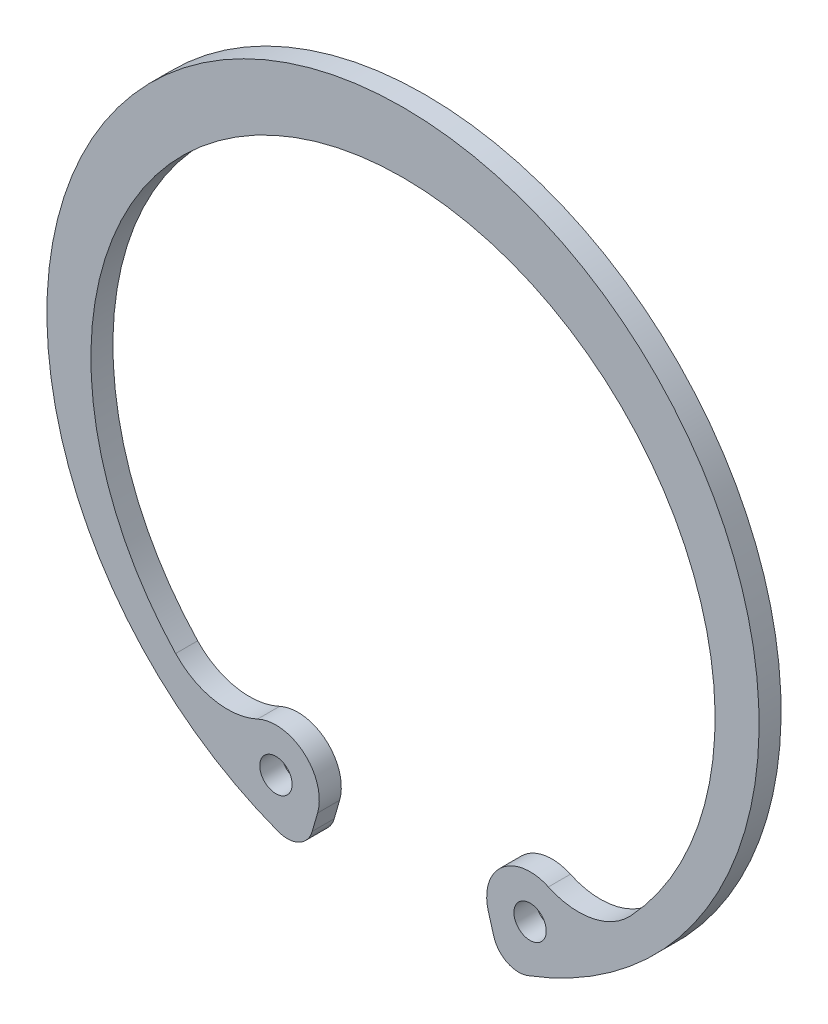
from build123d import *

# Parameters (mm, degrees)
SKETCH_3_R      = 1.25
EXTRUDE_1_DEPTH = 1.7


with BuildPart() as part:
    # Эскиз3 → Бобышка-Вытянуть1 (new body)
    with BuildSketch(Plane.XY):
        with BuildLine():
            Line((-7.01136277, -24.439204164), (-6.594823284, -22.997133444))
            ThreePointArc((-6.594823284, -22.997133444), (-7.634692218, -19.522622744), (-11.227983542, -19.030881496))
            ThreePointArc((-11.227983542, -19.030881496), (-14.589641394, -19.446371526), (-17.557236321, -17.813351066))
            ThreePointArc((-17.557236321, -17.813351066), (0, 22.8), (17.557236321, -17.813351066))
            ThreePointArc((17.557236321, -17.813351066), (14.589641394, -19.446371526), (11.227983542, -19.030881496))
            ThreePointArc((11.227983542, -19.030881496), (7.634692218, -19.522622744), (6.594823284, -22.997133444))
            Line((6.594823284, -22.997133444), (7.01136277, -24.439204164))
            ThreePointArc((7.01136277, -24.439204164), (8.034444052, -25.671075647), (9.633424702, -25.757467432))
            ThreePointArc((9.633424702, -25.757467432), (0, 27.5), (-9.633424702, -25.757467432))
            ThreePointArc((-9.633424702, -25.757467432), (-8.034444052, -25.671075647), (-7.01136277, -24.439204164))
        make_face()
        with Locations((-9.813250738, -22.067496567)):
            Circle(SKETCH_3_R, mode=Mode.SUBTRACT)
        with Locations((9.813250738, -22.067496567)):
            Circle(SKETCH_3_R, mode=Mode.SUBTRACT)
    extrude(amount=EXTRUDE_1_DEPTH)


solid = part.part
